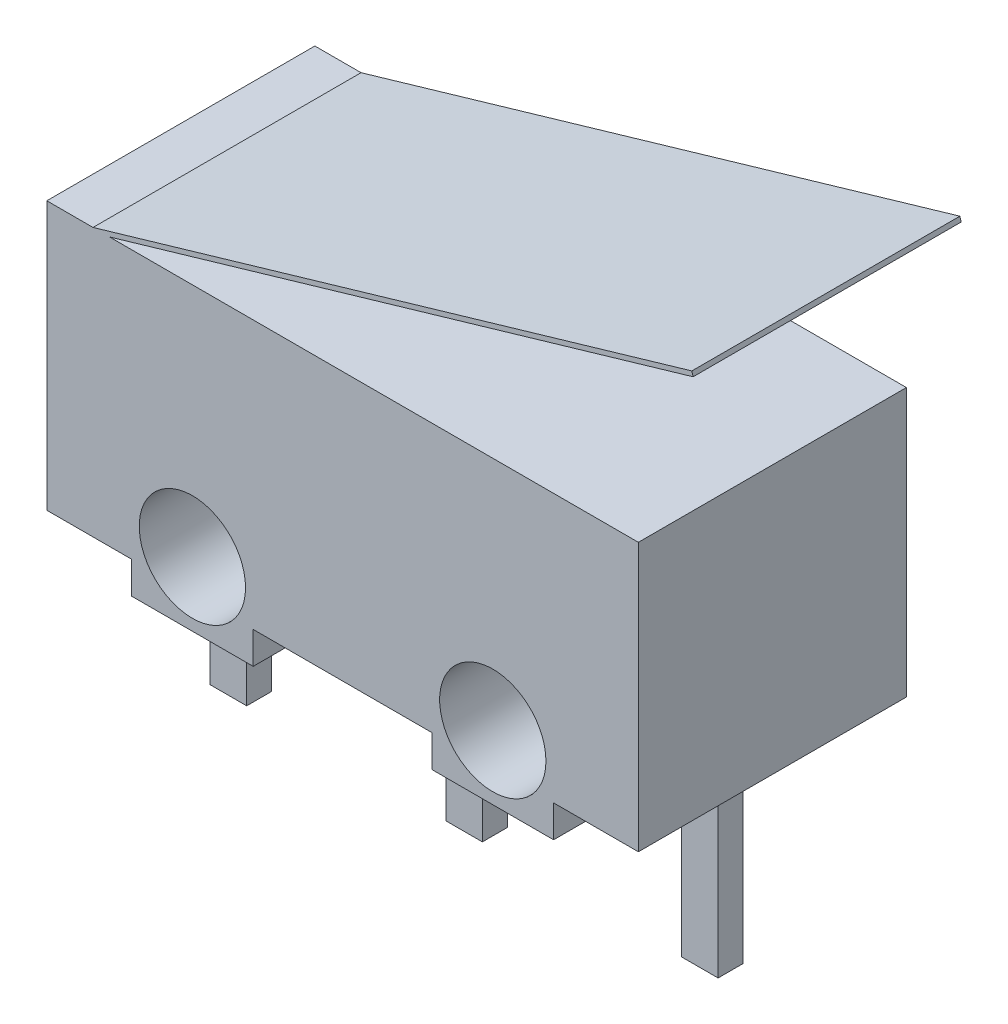
from build123d import *

# Parameters (mm, degrees)
SKETCH1_R           = 1.15
BOSS_EXTRUDE1_DEPTH = 2.9
EXTRUDE_THIN1_DEPTH = 5.8
BOSS_EXTRUDE2_REACH = 15.722
SKETCH4_W           = 0.79
SKETCH4_H           = 0.54
SKETCH5_W           = 0.89
SKETCH5_H           = 2.85
BOSS_EXTRUDE3_DEPTH = 0.56


with BuildPart() as part:
    # Sketch1 → Boss-Extrude1 (new body, symmetric)
    with BuildSketch(Plane.XY):
        Polygon((-6.4, -2.9), (-4.565838245, -2.9), (-4.565838245, -3.592341201), (-1.934161755, -3.592341201), (-1.934161755, -2.9), (1.934161755, -2.9), (1.934161755, -3.592341201), (4.565838245, -3.592341201), (4.565838245, -2.9), (6.4, -2.9), (6.4, 2.9), (-6.4, 2.9), align=None)
        with Locations((-3.25, -2.2)):
            Circle(SKETCH1_R, mode=Mode.SUBTRACT)
        with Locations((3.25, -2.2)):
            Circle(SKETCH1_R, mode=Mode.SUBTRACT)
    extrude(amount=BOSS_EXTRUDE1_DEPTH, both=True)

    # Sketch2 → Extrude-Thin1 (add)
    with BuildSketch(Plane.XY.offset(2.9)):
        Polygon((-5.4, 2.9), (7.557079146, 6.69), (7.58515322, 6.594021636), (-5.371925926, 2.804021636), align=None)
    extrude(amount=-EXTRUDE_THIN1_DEPTH)

    # Sketch4 → Boss-Extrude2 (add, up to next)
    with BuildSketch(Plane(origin=(0, -7.032341201, 0), x_dir=(-1, 0, 0), z_dir=(0, -1, 0)), mode=Mode.PRIVATE) as boss_extrude2_sk1:
        Rectangle(SKETCH4_W, SKETCH4_H)
    boss_extrude2_tool1 = extrude(boss_extrude2_sk1.sketch, amount=-BOSS_EXTRUDE2_REACH, mode=Mode.PRIVATE) - part.part
    add(boss_extrude2_tool1.solids().sort_by_distance((0, -7.032341, 0))[0])
    # Sketch4 → Boss-Extrude2 (add, up to next)
    with BuildSketch(Plane(origin=(0, -7.032341201, 0), x_dir=(-1, 0, 0), z_dir=(0, -1, 0)), mode=Mode.PRIVATE) as boss_extrude2_sk2:
        with Locations((5.1, 0)):
            Rectangle(SKETCH4_W, SKETCH4_H)
    boss_extrude2_tool2 = extrude(boss_extrude2_sk2.sketch, amount=-BOSS_EXTRUDE2_REACH, mode=Mode.PRIVATE) - part.part
    add(boss_extrude2_tool2.solids().sort_by_distance((-5.1, -7.032341, 0))[0])
    # Sketch4 → Boss-Extrude2 (add, up to next)
    with BuildSketch(Plane(origin=(0, -7.032341201, 0), x_dir=(-1, 0, 0), z_dir=(0, -1, 0)), mode=Mode.PRIVATE) as boss_extrude2_sk3:
        with Locations((-5.1, 0)):
            Rectangle(SKETCH4_W, SKETCH4_H)
    boss_extrude2_tool3 = extrude(boss_extrude2_sk3.sketch, amount=-BOSS_EXTRUDE2_REACH, mode=Mode.PRIVATE) - part.part
    add(boss_extrude2_tool3.solids().sort_by_distance((5.1, -7.032341, 0))[0])

    # Sketch5 → Boss-Extrude3 (add)
    with BuildSketch(Plane(origin=(0, 2.9, 0), x_dir=(1, 0, 0), z_dir=(0, 1, 0))):
        with Locations((-2.155, 0)):
            Rectangle(SKETCH5_W, SKETCH5_H)
    extrude(amount=BOSS_EXTRUDE3_DEPTH)


solid = part.part
